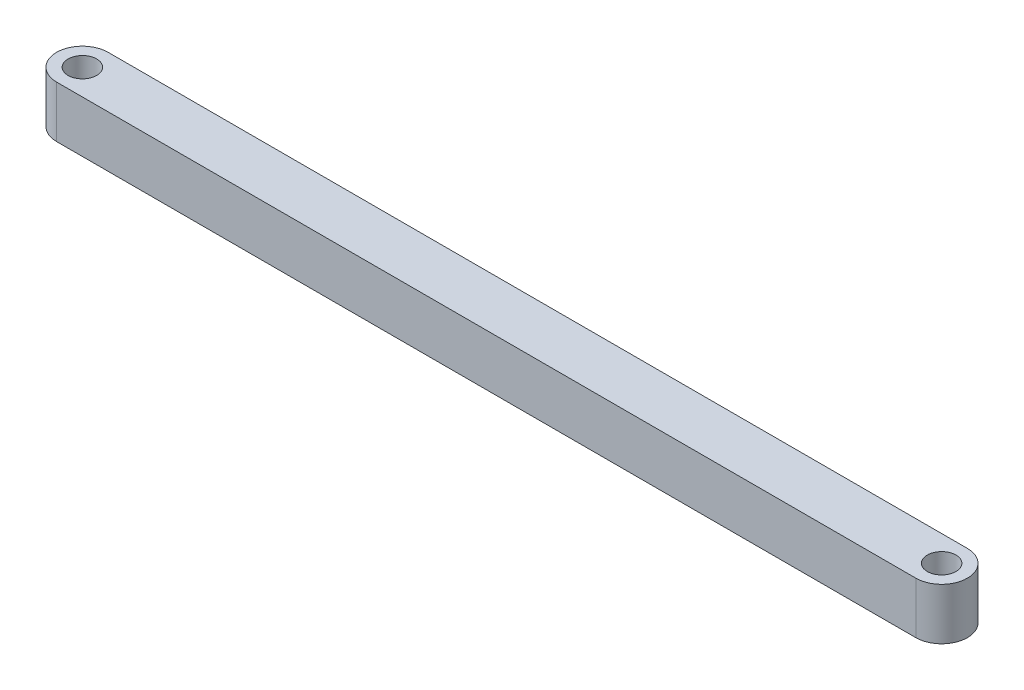
from build123d import *

# Parameters (mm, degrees)
SKETCH1_R           = 2.5
BOSS_EXTRUDE1_DEPTH = 9


with BuildPart() as part:
    # Sketch1 → Boss-Extrude1 (new body)
    with BuildSketch(Plane(origin=(0, 4.5, 0), x_dir=(1, 0, 0), z_dir=(0, 1, 0))):
        with BuildLine():
            Line((75, 4.5), (-75, 4.5))
            ThreePointArc((-75, 4.5), (-79.5, 0), (-75, -4.5))
            Line((-75, -4.5), (75, -4.5))
            ThreePointArc((75, -4.5), (79.5, 0), (75, 4.5))
        make_face()
        with Locations((75, 0)):
            Circle(SKETCH1_R, mode=Mode.SUBTRACT)
        with Locations((-75, 0)):
            Circle(SKETCH1_R, mode=Mode.SUBTRACT)
    extrude(amount=-BOSS_EXTRUDE1_DEPTH)


solid = part.part
